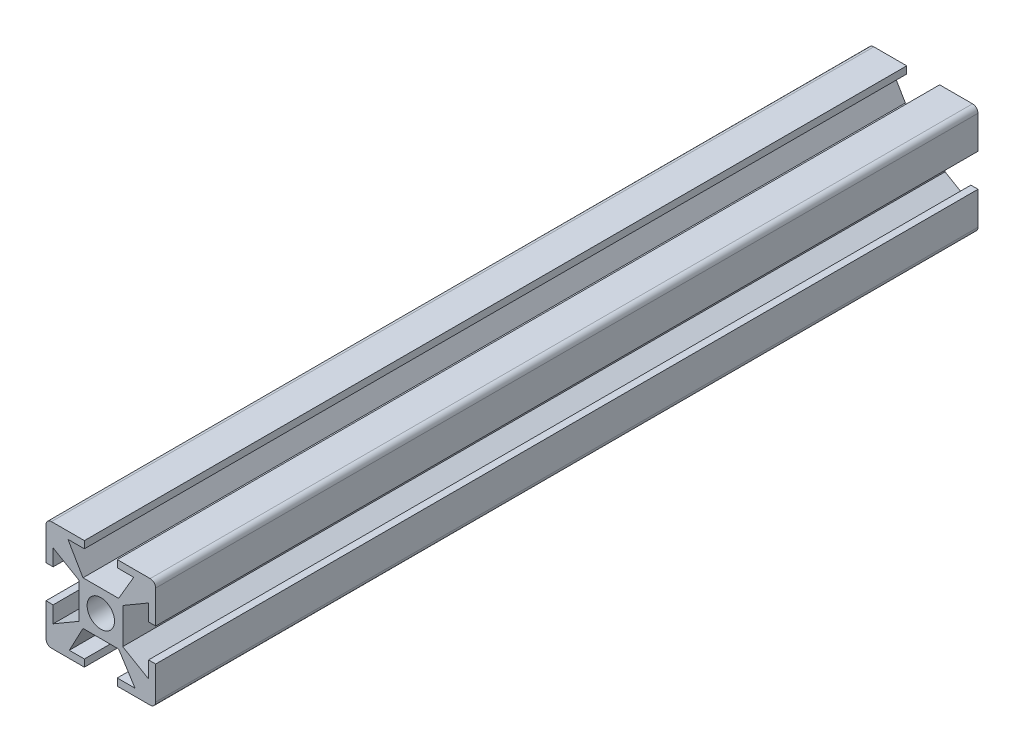
from build123d import *

# Parameters (mm, degrees)
CROQUIS1_W              = 8
CROQUIS1_H              = 8
CROQUIS1_R              = 2.5
SALIENTE_EXTRUIR4_DEPTH = 150


with BuildPart() as part:
    # Croquis1 → Saliente-Extruir4 (new body)
    with BuildSketch(Plane.XY):
        with BuildLine():
            Line((-3, 8.7), (-3, 10))
            Line((-3, 10), (-9, 10))
            ThreePointArc((-9, 10), (-9.707106781, 9.707106781), (-10, 9))
            Line((-10, 9), (-10, 3))
            Line((-10, 3), (-8.7, 3))
            Line((-8.7, 3), (-8.7, 6))
            Line((-8.7, 6), (-4, 3.25))
            Line((-4, 3.25), (-4, 4))
            Line((-4, 4), (-3.25, 4))
            Line((-3.25, 4), (-6, 8.7))
            Line((-6, 8.7), (-3, 8.7))
        make_face()
        with BuildLine():
            Line((9, 10), (3, 10))
            Line((3, 10), (3, 8.7))
            Line((3, 8.7), (6, 8.7))
            Line((6, 8.7), (3.25, 4))
            Line((3.25, 4), (4, 4))
            Line((4, 4), (4, 3.25))
            Line((4, 3.25), (8.7, 6))
            Line((8.7, 6), (8.7, 3))
            Line((8.7, 3), (10, 3))
            Line((10, 3), (10, 9))
            ThreePointArc((10, 9), (9.707106781, 9.707106781), (9, 10))
        make_face()
        with BuildLine():
            Line((10, -9), (10, -3))
            Line((10, -3), (8.7, -3))
            Line((8.7, -3), (8.7, -6))
            Line((8.7, -6), (4, -3.25))
            Line((4, -3.25), (4, -4))
            Line((4, -4), (3.25, -4))
            Line((3.25, -4), (6.25, -8.7))
            Line((6.25, -8.7), (3, -8.7))
            Line((3, -8.7), (3, -10))
            Line((3, -10), (9, -10))
            ThreePointArc((9, -10), (9.707106781, -9.707106781), (10, -9))
        make_face()
        with BuildLine():
            Line((-8.7, -3), (-10, -3))
            Line((-10, -3), (-10, -9))
            ThreePointArc((-10, -9), (-9.707106781, -9.707106781), (-9, -10))
            Line((-9, -10), (-3, -10))
            Line((-3, -10), (-3, -8.7))
            Line((-3, -8.7), (-5.75, -8.7))
            Line((-5.75, -8.7), (-3.25, -4))
            Line((-3.25, -4), (-4, -4))
            Line((-4, -4), (-4, -3.25))
            Line((-4, -3.25), (-8.7, -6))
            Line((-8.7, -6), (-8.7, -3))
        make_face()
        Rectangle(CROQUIS1_W, CROQUIS1_H)
        Circle(CROQUIS1_R, mode=Mode.SUBTRACT)
    extrude(amount=SALIENTE_EXTRUIR4_DEPTH)


solid = part.part
